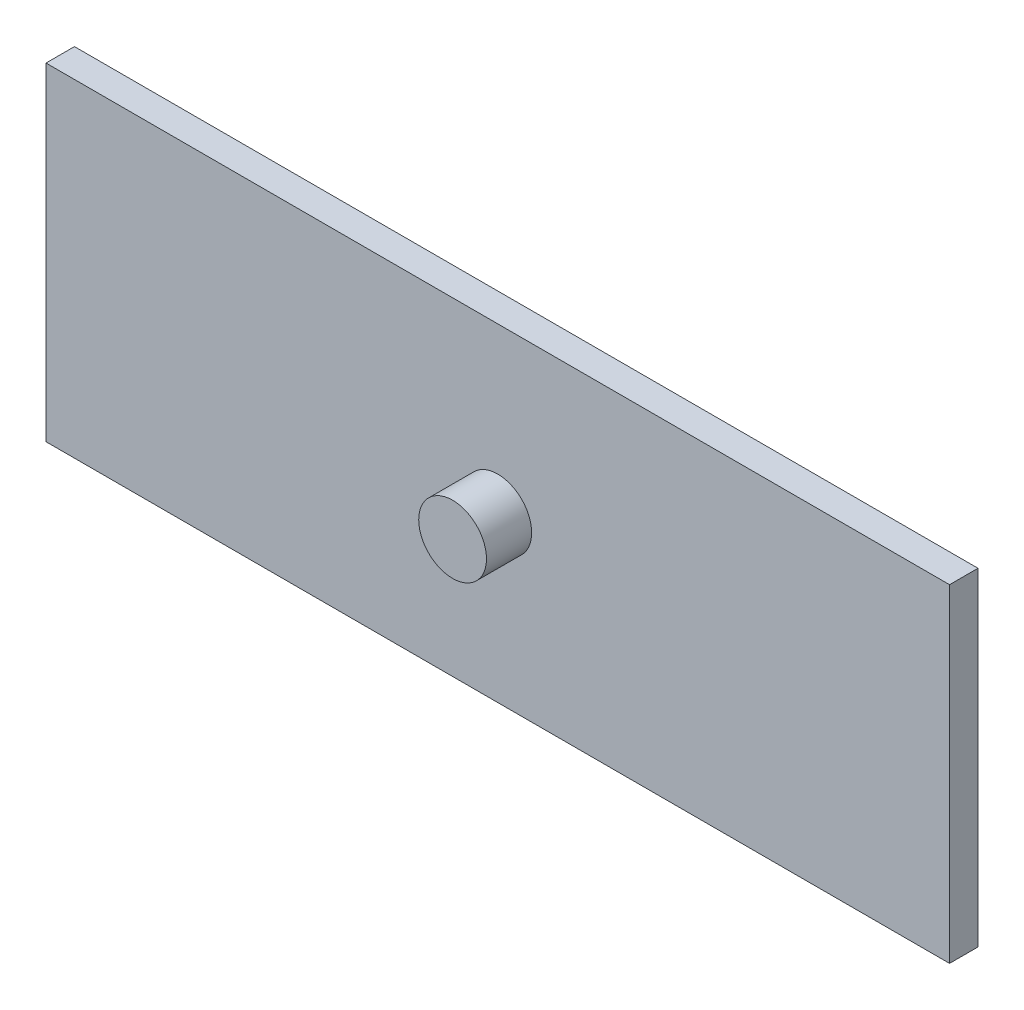
from build123d import *

# Parameters (mm, degrees)
SKETCH1_W           = 200
SKETCH1_H           = 72.6
BOSS_EXTRUDE1_DEPTH = 6.3
SKETCH2_R           = 7.5
BOSS_EXTRUDE2_DEPTH = 10


with BuildPart() as part:
    # Sketch1 → Boss-Extrude1 (new body)
    with BuildSketch(Plane.XY):
        with Locations((100, 36.3)):
            Rectangle(SKETCH1_W, SKETCH1_H)
    extrude(amount=BOSS_EXTRUDE1_DEPTH)

    # Sketch2 → Boss-Extrude2 (add)
    with BuildSketch(Plane.XY.offset(6.3)):
        with Locations((100, 36.3)):
            Circle(SKETCH2_R)
    extrude(amount=BOSS_EXTRUDE2_DEPTH)


solid = part.part
